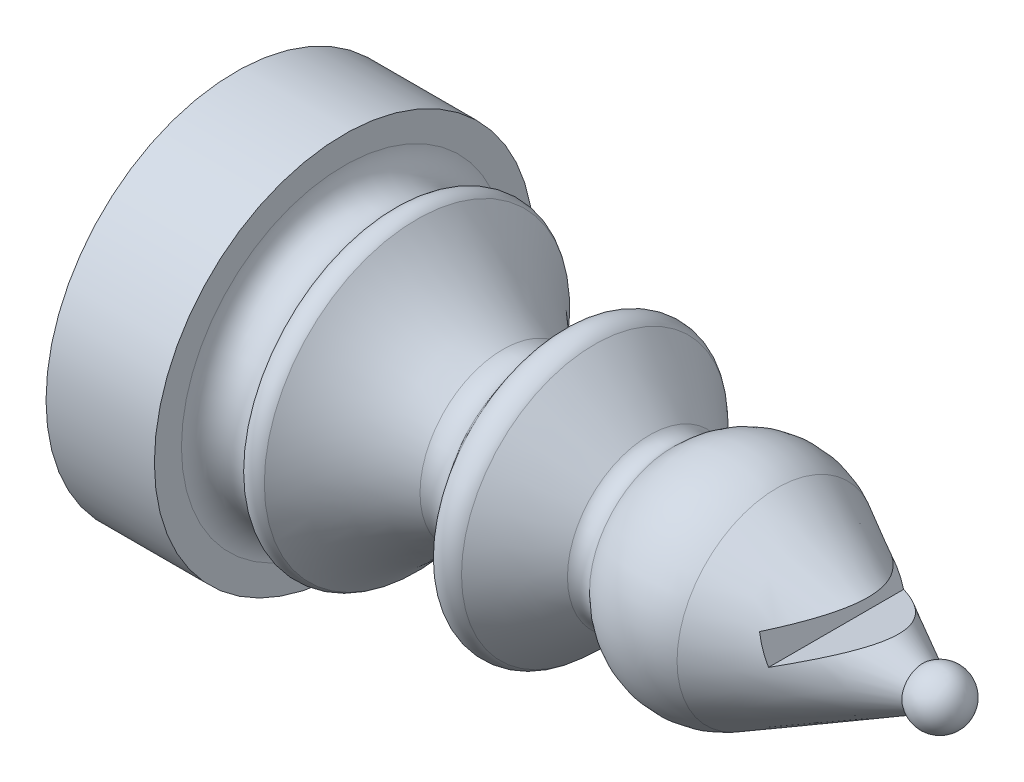
from build123d import *

# Parameters (mm, degrees)
CORTE_EXTRUS_O2_DEPTH = 5
CHANFRO1_SIZE         = 0.25
SKETCH1_R             = 7
BOSS_EXTRUDE1_DEPTH   = 2
BOSS_EXTRUDE2_START   = 2
SKETCH1_2_R           = 7
BOSS_EXTRUDE2_DEPTH   = 2
SKETCH2_R             = 6.05
CUT_EXTRUDE1_DEPTH    = 3.2


with BuildPart() as part:
    # Esboço1 → Revolução1 (revolve)
    with BuildSketch(Plane.XY):
        with BuildLine():
            Line((0, 0), (0, 6))
            Line((0, 6), (2, 6))
            ThreePointArc((2, 6), (2.814327742, 5.01738827), (3.931051625, 5.635112523))
            ThreePointArc((3.931051625, 5.635112523), (4.312225528, 5.771748243), (4.69339943, 5.635112523))
            ThreePointArc((4.69339943, 5.635112523), (6.152941065, 4.190020924), (7.867971219, 3.059877976))
            ThreePointArc((7.867971219, 3.059877976), (8.496410892, 2.978249662), (9.026483467, 3.325557406))
            Line((9.026483467, 3.325557406), (10.121420917, 4.80798808))
            ThreePointArc((10.121420917, 4.80798808), (10.663414926, 5.113748045), (11.25246109, 4.913070995))
            Line((11.25246109, 4.913070995), (13.278916417, 3.027727034))
            ThreePointArc((13.278916417, 3.027727034), (13.708810055, 2.86738462), (14.126306517, 3.057686836))
            ThreePointArc((14.126306517, 3.057686836), (15.94884844, 4.032561827), (17.987150284, 3.689974754))
            Line((17.987150284, 3.689974754), (23.373731502, 0.779607445))
            ThreePointArc((23.373731502, 0.779607445), (24.432279714, 0.901739568), (25, 0))
            Line((25, 0), (0, 0))
        make_face()
    revolve(axis=Axis((0, 0, 0), (1, 0, 0)))

    # Esboço3 → Corte-extrusão2 (cut, symmetric)
    with BuildSketch(Plane.XY):
        Polygon((23.022896677, 2.580968756), (19.779557922, 1.21054393), (20.168774633, 0.289397713), (23.412113388, 1.659822539), align=None)
    extrude(amount=CORTE_EXTRUS_O2_DEPTH, both=True, mode=Mode.SUBTRACT)

    # Chanfro1
    chanfro1_edges = [part.edges().sort_by_distance(p)[0] for p in [
        (0, -6, 0),
    ]]
    chamfer(chanfro1_edges, length=CHANFRO1_SIZE)

    # Sketch1 → Boss-Extrude1 (add)
    with BuildSketch(Plane.ZY):
        Circle(SKETCH1_R)
    extrude(amount=-BOSS_EXTRUDE1_DEPTH)

    # Sketch1_2 → Boss-Extrude2 (add)
    with BuildSketch(Plane.ZY.offset(BOSS_EXTRUDE2_START)):
        Circle(SKETCH1_2_R)
    extrude(amount=-BOSS_EXTRUDE2_DEPTH)

    # Sketch2 → Cut-Extrude1 (cut)
    with BuildSketch(Plane.ZY.offset(2)):
        Circle(SKETCH2_R)
    extrude(amount=-CUT_EXTRUDE1_DEPTH, mode=Mode.SUBTRACT)


solid = part.part
